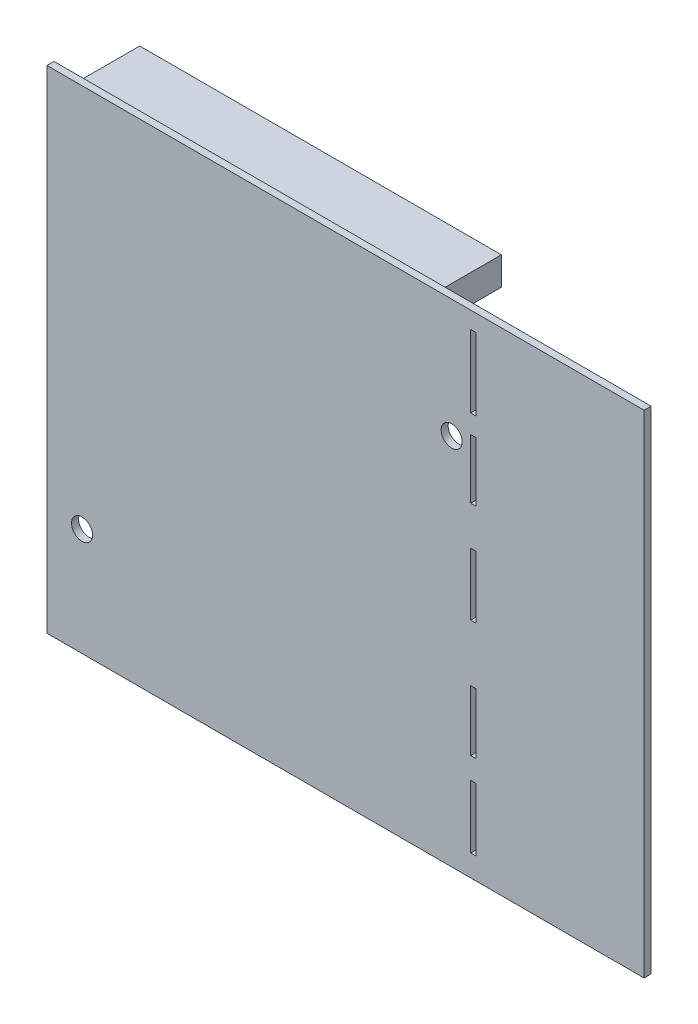
from build123d import *

# Parameters (mm, degrees)
SKETCH1_W             = 85
SKETCH1_H             = 70
BOSS_EXTRUDE1_DEPTH   = 1
SKETCH2_W             = 51.483328029
SKETCH2_H             = 4
BOSS_EXTRUDE2_DEPTH   = 10
BOSS_EXTRUDE2_2_DEPTH = 10
SKETCH3_W             = 0.7920512
SKETCH3_H             = 10.296665606
SKETCH3_H_2           = 8.462788072
SKETCH3_H_3           = 8.869103227
SKETCH3_H_4           = 8.612860113
SKETCH3_H_5           = 8.955645719
CUT_EXTRUDE1_DEPTH    = 10
SKETCH4_R             = 1.5
CUT_EXTRUDE3_DEPTH    = 33


with BuildPart() as part:
    # Sketch1 → Boss-Extrude1 (new body)
    with BuildSketch(Plane.XY):
        with Locations((-9.152236253, 6.399676375)):
            Rectangle(SKETCH1_W, SKETCH1_H)
    extrude(amount=BOSS_EXTRUDE1_DEPTH)

    # Sketch3 → Cut-Extrude1 (cut)
    with BuildSketch(Plane(origin=(0, 0, 0), x_dir=(-1, 0, 0), z_dir=(0, 0, -1))):
        with Locations((-9.064941357, 33.873952391)):
            Rectangle(SKETCH3_W, SKETCH3_H)
        with Locations((-9.064941357, 21.82838749)):
            Rectangle(SKETCH3_W, SKETCH3_H_2)
        with Locations((-9.064941357, 7.607144744)):
            Rectangle(SKETCH3_W, SKETCH3_H_3)
        with Locations((-9.064941357, -9.207607822)):
            Rectangle(SKETCH3_W, SKETCH3_H_4)
        with Locations((-9.064941357, -21.04821127)):
            Rectangle(SKETCH3_W, SKETCH3_H_5)
    extrude(amount=-CUT_EXTRUDE1_DEPTH, mode=Mode.SUBTRACT)

    # Sketch4 → Cut-Extrude3 (cut)
    with BuildSketch(Plane(origin=(0, 0, -10), x_dir=(-1, 0, 0), z_dir=(0, 0, -1))):
        with Locations((46.652236253, -13.269677869)):
            Circle(SKETCH4_R)
        with Locations((-5.962384938, 24.537566162)):
            Circle(SKETCH4_R)
    extrude(amount=-CUT_EXTRUDE3_DEPTH, mode=Mode.SUBTRACT)


with BuildPart() as body_2:
    # Sketch2 → Boss-Extrude2 (new body)
    with BuildSketch(Plane(origin=(0, 0, 0), x_dir=(-1, 0, 0), z_dir=(0, 0, -1))):
        with Locations((23.706177062, 37.399676375)):
            Rectangle(SKETCH2_W, SKETCH2_H)
    extrude(amount=BOSS_EXTRUDE2_DEPTH)


with BuildPart() as body_3:
    # Sketch2 → Boss-Extrude2 2 (new body)
    with BuildSketch(Plane(origin=(0, 0, 0), x_dir=(-1, 0, 0), z_dir=(0, 0, -1))):
        with Locations((23.706177062, -24.600323625)):
            Rectangle(SKETCH2_W, SKETCH2_H)
    extrude(amount=BOSS_EXTRUDE2_2_DEPTH)


solid = Compound([part.part, body_2.part, body_3.part])
